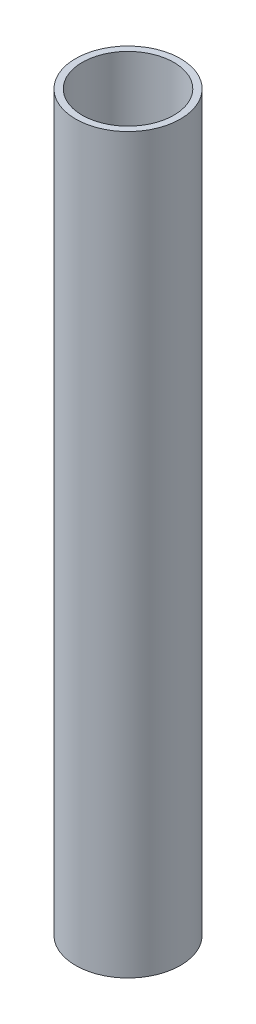
from build123d import *

# Parameters (mm, degrees)
SKETCH1_R           = 43.5864
SKETCH1_R_2         = 38.1
EXTRUDE_THIN1_DEPTH = 609.6


with BuildPart() as part:
    # Sketch1 → Extrude-Thin1 (new body)
    with BuildSketch(Plane(origin=(0, 0, 0), x_dir=(1, 0, 0), z_dir=(0, 1, 0))):
        Circle(SKETCH1_R)
        Circle(SKETCH1_R_2, mode=Mode.SUBTRACT)
    extrude(amount=EXTRUDE_THIN1_DEPTH)


solid = part.part
